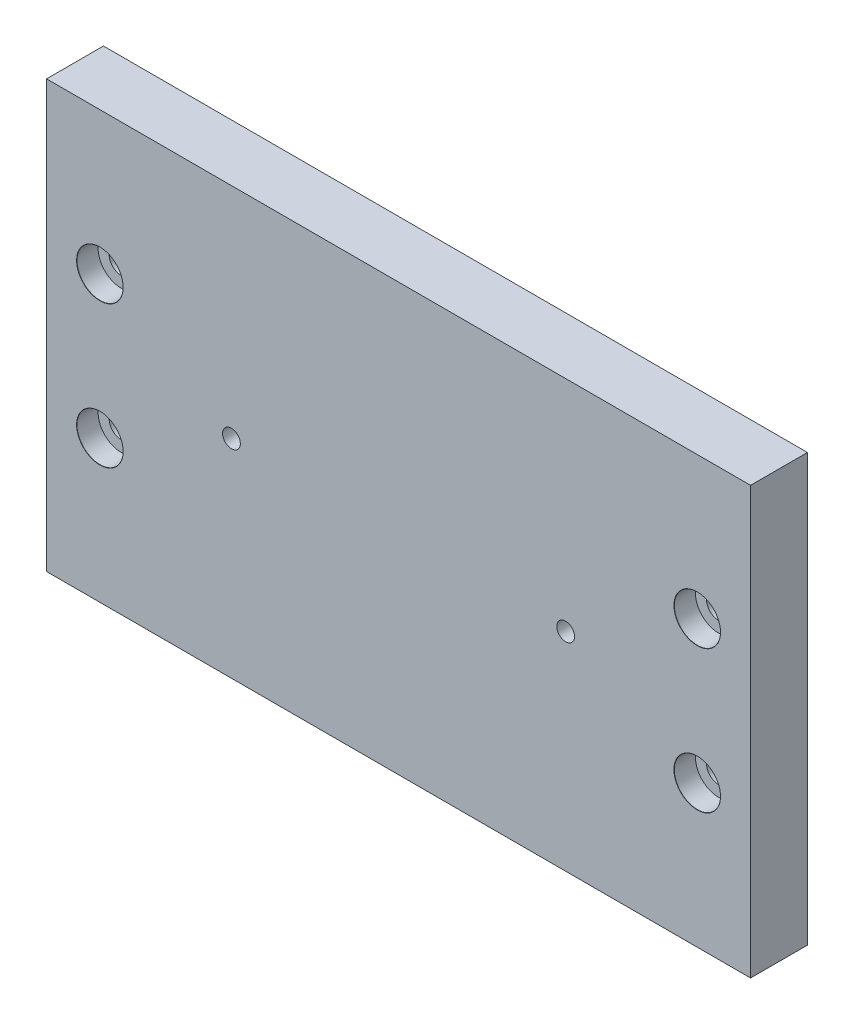
from build123d import *

# Parameters (mm, degrees)
SKETCH1_W                     = 99
SKETCH1_H                     = 60
BOSS_EXTRUDE1_DEPTH           = 4
CBORE_FOR_M3_SHCS1_AT_2_COUNT = 2
CBORE_FOR_M3_SHCS1_AT_2_PITCH = 20
M3X0_5_TAPPED_HOLE1_D         = 2.5


with BuildPart() as part:
    # Sketch1 → Boss-Extrude1 (new body, symmetric)
    with BuildSketch(Plane.XY):
        Rectangle(SKETCH1_W, SKETCH1_H)
    extrude(amount=BOSS_EXTRUDE1_DEPTH, both=True)

    # Sketch3 → CBORE for M3 SHCS1 (revolve, cut)
    with BuildSketch(Plane(origin=(-42, 10, 4), x_dir=(0, -1, 0), z_dir=(1, 0, 0))):
        Polygon((0, 0), (0, 8), (1.725, 8), (1.7, 7.975), (1.7, 3), (3.25, 3), (3.25, 0.025), (3.275, 0), align=None)
    cbore_for_m3_shcs1 = revolve(axis=Axis((-42, 10, 10.35), (0, 0, -1)), mode=Mode.SUBTRACT)

    # CBORE for M3 SHCS1 at 2: CBORE for M3 SHCS1 ×2
    with Locations(*[(0, -i * CBORE_FOR_M3_SHCS1_AT_2_PITCH, 0) for i in range(1, CBORE_FOR_M3_SHCS1_AT_2_COUNT)]):
        add(cbore_for_m3_shcs1, mode=Mode.SUBTRACT)

    # M3x0.5 Tapped Hole1 (through all)
    with Locations(Plane.XY.offset(4)):
        with Locations((-23.5, -0.8)):
            m3x0_5_tapped_hole1 = Hole(M3X0_5_TAPPED_HOLE1_D / 2)

    # Mirror1: M3x0.5 Tapped Hole1, CBORE for M3 SHCS1 across plane
    add(m3x0_5_tapped_hole1.mirror(Plane(origin=(0, 0, 0), x_dir=(0, 0, 1), z_dir=(1, 0, 0))), mode=Mode.SUBTRACT)
    add(cbore_for_m3_shcs1.mirror(Plane(origin=(0, 0, 0), x_dir=(0, 0, 1), z_dir=(1, 0, 0))), mode=Mode.SUBTRACT)

    # Mirror1 copy 1 sketch → Mirror1 copy 1 (revolve, cut)
    with BuildSketch(Plane(origin=(42, -10, 4), x_dir=(0, -1, 0), z_dir=(-1, 0, 0))):
        Polygon((0, 0), (0, -8), (1.725, -8), (1.7, -7.975), (1.7, -3), (3.25, -3), (3.25, -0.025), (3.275, 0), align=None)
    revolve(axis=Axis((42, -10, 10.35), (0, 0, 1)), mode=Mode.SUBTRACT)


solid = part.part
